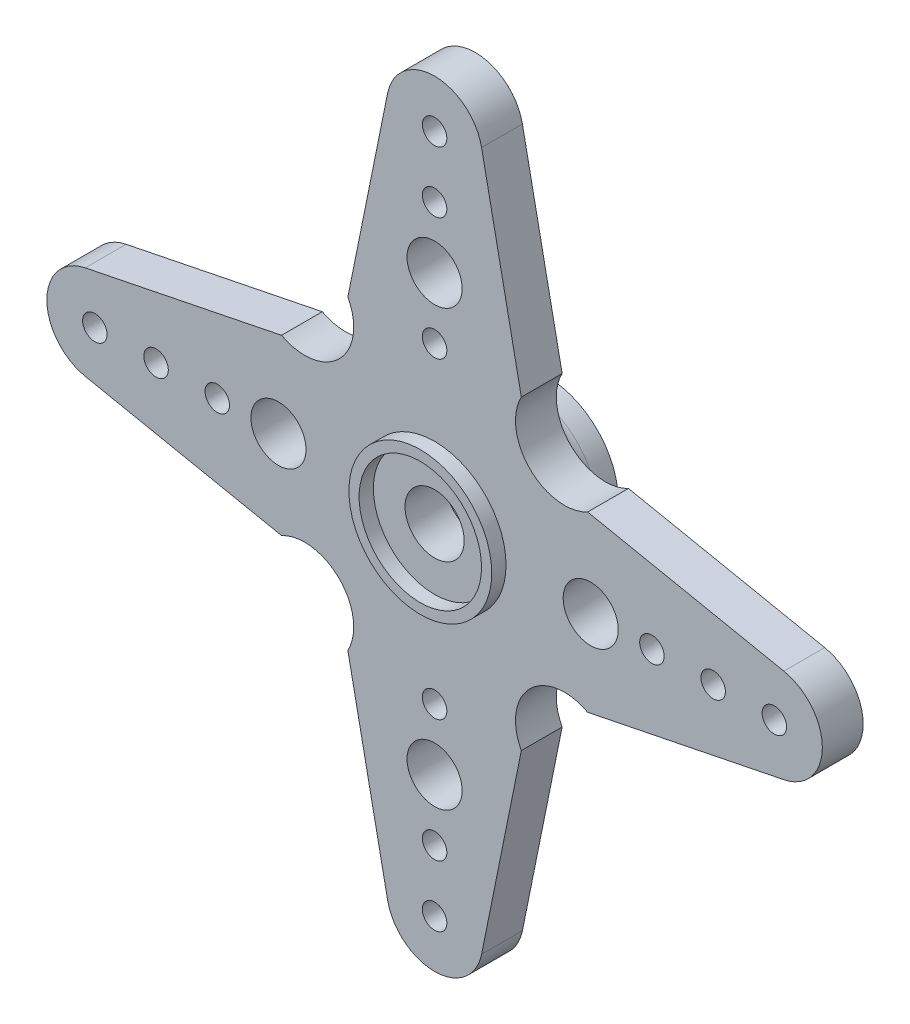
from build123d import *

# Parameters (mm, degrees)
AUFSATZ_LINEAR_AUSTRAGEN1_DEPTH           = 2
F_1_2_1_2_DURCHMESSER_BOHRUNG1_AT_2_COUNT = 2
F_1_2_1_2_DURCHMESSER_BOHRUNG1_AT_2_PITCH = 6
F_1_2_1_2_DURCHMESSER_BOHRUNG1_AT_3_COUNT = 2
F_1_2_1_2_DURCHMESSER_BOHRUNG1_AT_3_PITCH = 9
F_1_2_1_2_DURCHMESSER_BOHRUNG1_AT_4_COUNT = 2
F_1_2_1_2_DURCHMESSER_BOHRUNG1_AT_4_PITCH = 3
F_1_2_1_2_DURCHMESSER_BOHRUNG1_AT_5_COUNT = 2
F_1_2_1_2_DURCHMESSER_BOHRUNG1_AT_5_PITCH = 23.546655814
F_1_2_1_2_DURCHMESSER_BOHRUNG1_AT_6_COUNT = 2
F_1_2_1_2_DURCHMESSER_BOHRUNG1_AT_6_PITCH = 21.530095216
F_1_2_1_2_DURCHMESSER_BOHRUNG1_AT_7_COUNT = 2
F_1_2_1_2_DURCHMESSER_BOHRUNG1_AT_7_PITCH = 19.764741334
F_1_2_1_2_DURCHMESSER_BOHRUNG1_AT_8_COUNT = 2
F_1_2_1_2_DURCHMESSER_BOHRUNG1_AT_8_PITCH = 18.323345764
SKIZZE4_W                                 = 0.7
SKIZZE4_H                                 = 0.5
F_2_9_2_9_DURCHMESSER_BOHRUNG1_D          = 2.9
F_2_7_2_7_DIAMETER_HOLE1_D                = 2.7
F_2_7_2_7_DIAMETER_HOLE1_DEPTH            = 2.7


with BuildPart() as part:
    # Skizze1 → Aufsatz-Linear austragen1 (new body)
    with BuildSketch(Plane.XY):
        with BuildLine():
            Line((-2.30327731, 17.116276346), (-4.25, 7.5))
            ThreePointArc((-4.25, 7.5), (-4.666990822, 4.666990822), (-7.5, 4.25))
            Line((-7.5, 4.25), (-17.116276346, 2.30327731))
            ThreePointArc((-17.116276346, 2.30327731), (-19, 0), (-17.116276346, -2.30327731))
            Line((-17.116276346, -2.30327731), (-7.5, -4.25))
            ThreePointArc((-7.5, -4.25), (-4.666990822, -4.666990822), (-4.25, -7.5))
            Line((-4.25, -7.5), (-2.30327731, -17.116276346))
            ThreePointArc((-2.30327731, -17.116276346), (0, -19), (2.30327731, -17.116276346))
            Line((2.30327731, -17.116276346), (4.25, -7.5))
            ThreePointArc((4.25, -7.5), (4.666990822, -4.666990822), (7.5, -4.25))
            Line((7.5, -4.25), (17.116276346, -2.30327731))
            ThreePointArc((17.116276346, -2.30327731), (19, 0), (17.116276346, 2.30327731))
            Line((17.116276346, 2.30327731), (7.5, 4.25))
            ThreePointArc((7.5, 4.25), (4.666990822, 4.666990822), (4.25, 7.5))
            Line((4.25, 7.5), (2.30327731, 17.116276346))
            ThreePointArc((2.30327731, 17.116276346), (0, 19), (-2.30327731, 17.116276346))
        make_face()
    extrude(amount=AUFSATZ_LINEAR_AUSTRAGEN1_DEPTH)

    # Skizze2 → Ø1.2 (1.2) Durchmesser Bohrung1 (revolve, cut)
    with BuildSketch(Plane(origin=(0, 16.65, 0), x_dir=(0, 1, 0), z_dir=(1, 0, 0))):
        Polygon((0, 0), (0, 10.360516371), (0.6, 10), (0.6, 0), align=None)
    f_1_2_1_2_durchmesser_bohrung1 = revolve(axis=Axis((0, 16.65, -6.35), (0, 0, 1)), mode=Mode.SUBTRACT)

    # Ø1.2 (1.2) Durchmesser Bohrung1 at 2: Ø1.2 (1.2) Durchmesser Bohrung1 ×2
    with Locations(*[(0, -i * F_1_2_1_2_DURCHMESSER_BOHRUNG1_AT_2_PITCH, 0) for i in range(1, F_1_2_1_2_DURCHMESSER_BOHRUNG1_AT_2_COUNT)]):
        add(f_1_2_1_2_durchmesser_bohrung1, mode=Mode.SUBTRACT)

    # Ø1.2 (1.2) Durchmesser Bohrung1 at 3: Ø1.2 (1.2) Durchmesser Bohrung1 ×2
    with Locations(*[(0, -i * F_1_2_1_2_DURCHMESSER_BOHRUNG1_AT_3_PITCH, 0) for i in range(1, F_1_2_1_2_DURCHMESSER_BOHRUNG1_AT_3_COUNT)]):
        add(f_1_2_1_2_durchmesser_bohrung1, mode=Mode.SUBTRACT)

    # Ø1.2 (1.2) Durchmesser Bohrung1 at 4: Ø1.2 (1.2) Durchmesser Bohrung1 ×2
    with Locations(*[(0, -i * F_1_2_1_2_DURCHMESSER_BOHRUNG1_AT_4_PITCH, 0) for i in range(1, F_1_2_1_2_DURCHMESSER_BOHRUNG1_AT_4_COUNT)]):
        add(f_1_2_1_2_durchmesser_bohrung1, mode=Mode.SUBTRACT)

    # Ø1.2 (1.2) Durchmesser Bohrung1 at 5: Ø1.2 (1.2) Durchmesser Bohrung1 ×2
    with Locations(*[Vector(-0.707106781, -0.707106781, 0) * (i * F_1_2_1_2_DURCHMESSER_BOHRUNG1_AT_5_PITCH) for i in range(1, F_1_2_1_2_DURCHMESSER_BOHRUNG1_AT_5_COUNT)]):
        add(f_1_2_1_2_durchmesser_bohrung1, mode=Mode.SUBTRACT)

    # Ø1.2 (1.2) Durchmesser Bohrung1 at 6: Ø1.2 (1.2) Durchmesser Bohrung1 ×2
    with Locations(*[Vector(-0.633996267, -0.773336106, 0) * (i * F_1_2_1_2_DURCHMESSER_BOHRUNG1_AT_6_PITCH) for i in range(1, F_1_2_1_2_DURCHMESSER_BOHRUNG1_AT_6_COUNT)]):
        add(f_1_2_1_2_durchmesser_bohrung1, mode=Mode.SUBTRACT)

    # Ø1.2 (1.2) Durchmesser Bohrung1 at 7: Ø1.2 (1.2) Durchmesser Bohrung1 ×2
    with Locations(*[Vector(-0.538838319, -0.842409203, 0) * (i * F_1_2_1_2_DURCHMESSER_BOHRUNG1_AT_7_PITCH) for i in range(1, F_1_2_1_2_DURCHMESSER_BOHRUNG1_AT_7_COUNT)]):
        add(f_1_2_1_2_durchmesser_bohrung1, mode=Mode.SUBTRACT)

    # Ø1.2 (1.2) Durchmesser Bohrung1 at 8: Ø1.2 (1.2) Durchmesser Bohrung1 ×2
    with Locations(*[Vector(-0.417500172, -0.908676844, 0) * (i * F_1_2_1_2_DURCHMESSER_BOHRUNG1_AT_8_PITCH) for i in range(1, F_1_2_1_2_DURCHMESSER_BOHRUNG1_AT_8_COUNT)]):
        add(f_1_2_1_2_durchmesser_bohrung1, mode=Mode.SUBTRACT)

    # Spiegeln1: Ø1.2 (1.2) Durchmesser Bohrung1 across plane
    add(f_1_2_1_2_durchmesser_bohrung1.mirror(Plane(origin=(0, 0, 0), x_dir=(0, 0, 1), z_dir=(1, 0, 0))), mode=Mode.SUBTRACT)

    # Spiegeln1 copy 1 sketch → Spiegeln1 copy 1 (revolve, cut)
    with BuildSketch(Plane(origin=(0, 10.65, 0), x_dir=(0, 1, 0), z_dir=(-1, 0, 0))):
        Polygon((0, 0), (0, -10.360516371), (0.6, -10), (0.6, 0), align=None)
    revolve(axis=Axis((0, 10.65, -6.35), (0, 0, -1)), mode=Mode.SUBTRACT)

    # Spiegeln1 copy 2 sketch → Spiegeln1 copy 2 (revolve, cut)
    with BuildSketch(Plane(origin=(0, 7.65, 0), x_dir=(0, 1, 0), z_dir=(-1, 0, 0))):
        Polygon((0, 0), (0, -10.360516371), (0.6, -10), (0.6, 0), align=None)
    revolve(axis=Axis((0, 7.65, -6.35), (0, 0, -1)), mode=Mode.SUBTRACT)

    # Spiegeln1 copy 3 sketch → Spiegeln1 copy 3 (revolve, cut)
    with BuildSketch(Plane(origin=(0, 13.65, 0), x_dir=(0, 1, 0), z_dir=(-1, 0, 0))):
        Polygon((0, 0), (0, -10.360516371), (0.6, -10), (0.6, 0), align=None)
    revolve(axis=Axis((0, 13.65, -6.35), (0, 0, -1)), mode=Mode.SUBTRACT)

    # Spiegeln1 copy 4 sketch → Spiegeln1 copy 4 (revolve, cut)
    with BuildSketch(Plane(origin=(16.65, 0, 0), x_dir=(0, 1, 0), z_dir=(-1, 0, 0))):
        Polygon((0, 0), (0, -10.360516371), (0.6, -10), (0.6, 0), align=None)
    revolve(axis=Axis((16.65, 0, -6.35), (0, 0, -1)), mode=Mode.SUBTRACT)

    # Spiegeln1 copy 5 sketch → Spiegeln1 copy 5 (revolve, cut)
    with BuildSketch(Plane(origin=(13.65, 0, 0), x_dir=(0, 1, 0), z_dir=(-1, 0, 0))):
        Polygon((0, 0), (0, -10.360516371), (0.6, -10), (0.6, 0), align=None)
    revolve(axis=Axis((13.65, 0, -6.35), (0, 0, -1)), mode=Mode.SUBTRACT)

    # Spiegeln1 copy 6 sketch → Spiegeln1 copy 6 (revolve, cut)
    with BuildSketch(Plane(origin=(10.65, 0, 0), x_dir=(0, 1, 0), z_dir=(-1, 0, 0))):
        Polygon((0, 0), (0, -10.360516371), (0.6, -10), (0.6, 0), align=None)
    revolve(axis=Axis((10.65, 0, -6.35), (0, 0, -1)), mode=Mode.SUBTRACT)

    # Spiegeln1 copy 7 sketch → Spiegeln1 copy 7 (revolve, cut)
    with BuildSketch(Plane(origin=(7.65, 0, 0), x_dir=(0, 1, 0), z_dir=(-1, 0, 0))):
        Polygon((0, 0), (0, -10.360516371), (0.6, -10), (0.6, 0), align=None)
    revolve(axis=Axis((7.65, 0, -6.35), (0, 0, -1)), mode=Mode.SUBTRACT)

    # Spiegeln2: Ø1.2 (1.2) Durchmesser Bohrung1 across plane
    add(f_1_2_1_2_durchmesser_bohrung1.mirror(Plane.ZX), mode=Mode.SUBTRACT)

    # Spiegeln2 copy 1 sketch → Spiegeln2 copy 1 (revolve, cut)
    with BuildSketch(Plane(origin=(0, -10.65, 0), x_dir=(0, -1, 0), z_dir=(1, 0, 0))):
        Polygon((0, 0), (0, -10.360516371), (0.6, -10), (0.6, 0), align=None)
    revolve(axis=Axis((0, -10.65, -6.35), (0, 0, -1)), mode=Mode.SUBTRACT)

    # Spiegeln2 copy 2 sketch → Spiegeln2 copy 2 (revolve, cut)
    with BuildSketch(Plane(origin=(0, -7.65, 0), x_dir=(0, -1, 0), z_dir=(1, 0, 0))):
        Polygon((0, 0), (0, -10.360516371), (0.6, -10), (0.6, 0), align=None)
    revolve(axis=Axis((0, -7.65, -6.35), (0, 0, -1)), mode=Mode.SUBTRACT)

    # Spiegeln2 copy 3 sketch → Spiegeln2 copy 3 (revolve, cut)
    with BuildSketch(Plane(origin=(0, -13.65, 0), x_dir=(0, -1, 0), z_dir=(1, 0, 0))):
        Polygon((0, 0), (0, -10.360516371), (0.6, -10), (0.6, 0), align=None)
    revolve(axis=Axis((0, -13.65, -6.35), (0, 0, -1)), mode=Mode.SUBTRACT)

    # Spiegeln2 copy 4 sketch → Spiegeln2 copy 4 (revolve, cut)
    with BuildSketch(Plane(origin=(-16.65, 0, 0), x_dir=(0, -1, 0), z_dir=(1, 0, 0))):
        Polygon((0, 0), (0, -10.360516371), (0.6, -10), (0.6, 0), align=None)
    revolve(axis=Axis((-16.65, 0, -6.35), (0, 0, -1)), mode=Mode.SUBTRACT)

    # Spiegeln2 copy 5 sketch → Spiegeln2 copy 5 (revolve, cut)
    with BuildSketch(Plane(origin=(-13.65, 0, 0), x_dir=(0, -1, 0), z_dir=(1, 0, 0))):
        Polygon((0, 0), (0, -10.360516371), (0.6, -10), (0.6, 0), align=None)
    revolve(axis=Axis((-13.65, 0, -6.35), (0, 0, -1)), mode=Mode.SUBTRACT)

    # Spiegeln2 copy 6 sketch → Spiegeln2 copy 6 (revolve, cut)
    with BuildSketch(Plane(origin=(-10.65, 0, 0), x_dir=(0, -1, 0), z_dir=(1, 0, 0))):
        Polygon((0, 0), (0, -10.360516371), (0.6, -10), (0.6, 0), align=None)
    revolve(axis=Axis((-10.65, 0, -6.35), (0, 0, -1)), mode=Mode.SUBTRACT)

    # Spiegeln2 copy 7 sketch → Spiegeln2 copy 7 (revolve, cut)
    with BuildSketch(Plane(origin=(-7.65, 0, 0), x_dir=(0, -1, 0), z_dir=(1, 0, 0))):
        Polygon((0, 0), (0, -10.360516371), (0.6, -10), (0.6, 0), align=None)
    revolve(axis=Axis((-7.65, 0, -6.35), (0, 0, -1)), mode=Mode.SUBTRACT)

    # Skizze4 → Rotation1 (revolve)
    with BuildSketch(Plane(origin=(0, 0, 0), x_dir=(0, 0, -1), z_dir=(1, 0, 0))):
        with BuildLine():
            Line((0, 5), (1, 5))
            ThreePointArc((1, 5), (1.439339828, 3.939339828), (2.5, 3.5))
            Line((2.5, 3.5), (3.5, 3.5))
            Line((3.5, 3.5), (3.5, 3))
            Line((3.5, 3), (0, 3))
            Line((0, 3), (0, 5))
        make_face()
        with Locations((-2.35, 3.25)):
            Rectangle(SKIZZE4_W, SKIZZE4_H)
    revolve(axis=Axis((0, 0, 3.110475716), (0, 0, -1)))

    # Ø2.9 (2.9) Durchmesser Bohrung1 (through all)
    with Locations(Plane(origin=(0, 0, 0), x_dir=(-1, 0, 0), z_dir=(0, 0, -1))):
        with Locations((0, 0)):
            Hole(F_2_9_2_9_DURCHMESSER_BOHRUNG1_D / 2)

    # Ø2.7 (2.7) Diameter Hole1
    with Locations(Plane(origin=(0, 0, 0), x_dir=(-1, 0, 0), z_dir=(0, 0, -1))):
        with Locations((-7.65, 0), (7.65, 0), (0, 10.65), (0, -10.65)):
            Hole(F_2_7_2_7_DIAMETER_HOLE1_D / 2, depth=F_2_7_2_7_DIAMETER_HOLE1_DEPTH)


solid = part.part
